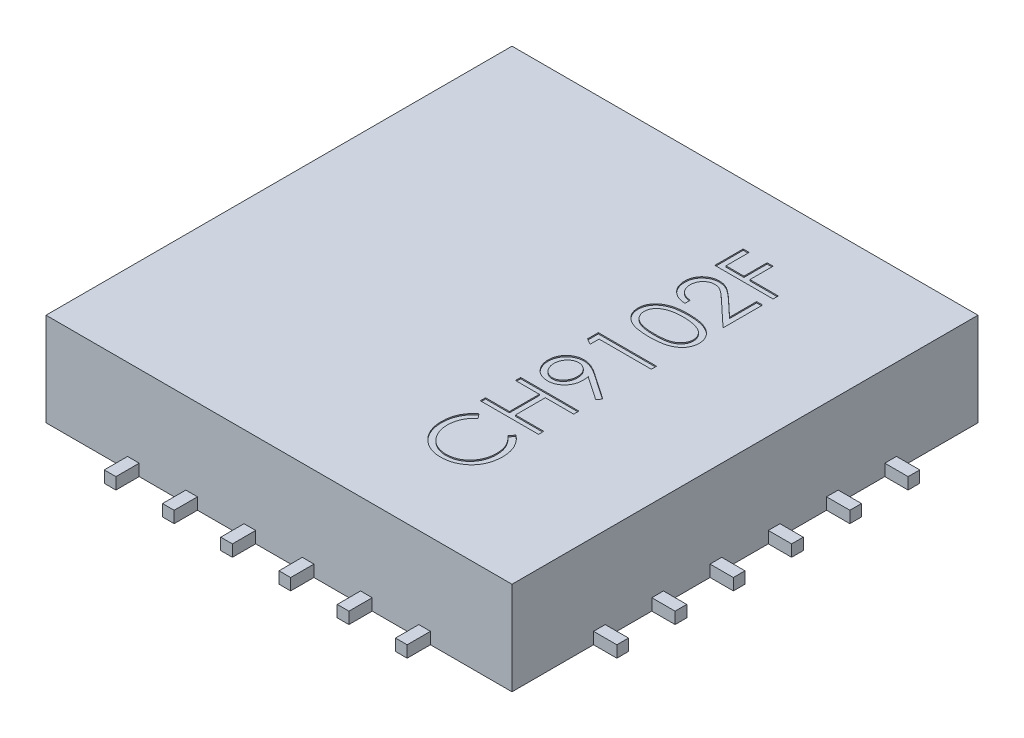
from build123d import *

# Parameters (mm, degrees)
BASES_W                = 4
BASES_H                = 4
BASE_DEPTH             = 0.8
SOLDERCONNECTIONS_W    = 0.2
SOLDERCONNECTIONS_H    = 0.1
SOLDERCONNECTION_DEPTH = 0.1
SC_CP_COUNT            = 4
PARTNO_DEPTH           = 0.01


with BuildPart() as part:
    # BaseS → Base (new body)
    with BuildSketch(Plane(origin=(0, 0, 0), x_dir=(1, 0, 0), z_dir=(0, 1, 0))):
        Rectangle(BASES_W, BASES_H)
    extrude(amount=BASE_DEPTH)

    # SolderConnectionS → SolderConnection (add)
    with BuildSketch(Plane(origin=(0, 0, 0), x_dir=(1, 0, 0), z_dir=(0, 1, 0))):
        with Locations((2.1, -1.25)):
            Rectangle(SOLDERCONNECTIONS_W, SOLDERCONNECTIONS_H)
        with Locations((2.1, -0.75)):
            Rectangle(SOLDERCONNECTIONS_W, SOLDERCONNECTIONS_H)
        with Locations((2.1, -0.25)):
            Rectangle(SOLDERCONNECTIONS_W, SOLDERCONNECTIONS_H)
        with Locations((2.1, 0.25)):
            Rectangle(SOLDERCONNECTIONS_W, SOLDERCONNECTIONS_H)
        with Locations((2.1, 0.75)):
            Rectangle(SOLDERCONNECTIONS_W, SOLDERCONNECTIONS_H)
        with Locations((2.1, 1.25)):
            Rectangle(SOLDERCONNECTIONS_W, SOLDERCONNECTIONS_H)
    solderconnection = extrude(amount=SOLDERCONNECTION_DEPTH)

    # SC CP: SolderConnection ×4 about axis
    sc_cp_axis = Axis((0, 0.84, 0), (0, -1, 0))
    for i in range(1, SC_CP_COUNT):
        add(solderconnection.rotate(sc_cp_axis, i * 360 / SC_CP_COUNT))

    # PartNoS → PartNo (cut)
    # profile 1 of 7: a face of its own
    with BuildSketch(Plane(origin=(0, 0.8, 0), x_dir=(1, 0, 0), z_dir=(0, 1, 0))):
        with BuildLine():
            Line((0.591746795, -0.874358974), (0.621794872, -0.913621795))
            add(Edge.make_bspline(
                [(0.621794872, -0.913621795), (0.61845692, -0.916422665), (0.61182602, -0.921986643), (0.602514008, -0.930937535), (0.593792826, -0.94026792), (0.58560644, -0.949964815), (0.578283878, -0.960252628), (0.571254852, -0.970739365), (0.565100698, -0.981806055), (0.557582628, -0.997031465), (0.54990858, -1.017026558), (0.543308235, -1.042110107), (0.53914621, -1.068330939), (0.538692376, -1.086215626), (0.538461538, -1.0953125)],
                knots=[0, 0, 0, 0, 0.75789156, 1.505565099, 2.245254514, 2.979266606, 3.711207489, 4.440978832, 5.174393176, 5.91211879, 7.394186119, 8.890401545, 10.418332761, 12, 12, 12, 12], degree=3))
            add(Edge.make_bspline(
                [(0.538461538, -1.0953125), (0.538519247, -1.1003244), (0.53863413, -1.110301685), (0.540149719, -1.125108609), (0.542279892, -1.139639045), (0.545440652, -1.15388354), (0.549436741, -1.167823963), (0.5542118, -1.181551449), (0.560119633, -1.194867251), (0.566649391, -1.207955562), (0.574024716, -1.220495481), (0.582069568, -1.232360371), (0.590693407, -1.243507651), (0.599930445, -1.253943597), (0.609732138, -1.263688239), (0.620208298, -1.272618954), (0.631246931, -1.280855063), (0.642857204, -1.288349628), (0.654930986, -1.295096476), (0.667537211, -1.300769527), (0.680460033, -1.305724331), (0.693791068, -1.309706707), (0.70744171, -1.312834341), (0.72146851, -1.314996643), (0.735844874, -1.316494668), (0.745589045, -1.316609023), (0.750500801, -1.316666667)],
                knots=[0, 0, 0, 0, 1.054877232, 2.099964208, 3.13098259, 4.145888998, 5.169474743, 6.183358035, 7.203388855, 8.234598956, 9.261847606, 10.264062591, 11.251197969, 12.227332808, 13.196685059, 14.158975844, 15.123498106, 16.094582253, 17.066912473, 18.032714859, 19.002806091, 19.979168736, 20.95977404, 21.949109834, 22.966205168, 24, 24, 24, 24], degree=3))
            add(Edge.make_bspline(
                [(0.750500801, -1.316666667), (0.757890825, -1.316485984), (0.772400157, -1.316131238), (0.79365544, -1.312987476), (0.814037562, -1.308171849), (0.833408519, -1.3010727), (0.85192979, -1.292144394), (0.869376768, -1.28100433), (0.886005055, -1.268053353), (0.901411924, -1.2531586), (0.915485114, -1.23681448), (0.927878107, -1.219279179), (0.93820879, -1.200595679), (0.946805358, -1.180970454), (0.953413461, -1.160252436), (0.958065479, -1.138478893), (0.961100076, -1.115697179), (0.961390603, -1.100130122), (0.961538462, -1.092207532)],
                knots=[0, 0, 0, 0, 1.029159485, 2.020618137, 2.987588728, 3.942669054, 4.889339625, 5.846988364, 6.821327795, 7.821533711, 8.827683044, 9.822769455, 10.807800696, 11.797391277, 12.803701919, 13.832062008, 14.896664671, 16, 16, 16, 16], degree=3))
            add(Edge.make_bspline(
                [(0.961538462, -1.092207532), (0.961297207, -1.083478576), (0.960822361, -1.066297904), (0.956799611, -1.041102471), (0.950277052, -1.016983076), (0.941148777, -0.993938421), (0.929282307, -0.972033472), (0.914896896, -0.951233949), (0.897855706, -0.931522296), (0.88484383, -0.919669256), (0.878205128, -0.913621795)],
                knots=[0, 0, 0, 0, 1.028121516, 2.023589091, 2.998037872, 3.967518031, 4.937445131, 5.927275754, 6.942489185, 8, 8, 8, 8], degree=3))
            Line((0.878205128, -0.913621795), (0.907952724, -0.874358974))
            add(Edge.make_bspline(
                [(0.907952724, -0.874358974), (0.912029505, -0.877518815), (0.920163539, -0.883823361), (0.931633018, -0.894030006), (0.942411492, -0.904790044), (0.952445132, -0.916131133), (0.961775469, -0.928073262), (0.970407573, -0.940615336), (0.978295631, -0.953746648), (0.9855412, -0.967362898), (0.991920677, -0.981495461), (0.997573827, -0.996019924), (1.00225401, -1.011025341), (1.006212919, -1.0263854), (1.0090358, -1.042238824), (1.011283721, -1.058401329), (1.012617355, -1.075024191), (1.012752186, -1.086228946), (1.012820513, -1.091907051)],
                knots=[0, 0, 0, 0, 0.986911346, 1.969095443, 2.935967484, 3.900112155, 4.865124501, 5.834589912, 6.812044781, 7.795288262, 8.784678562, 9.777857908, 10.776141921, 11.791195789, 12.811324908, 13.855933174, 14.913475973, 16, 16, 16, 16], degree=3))
            add(Edge.make_bspline(
                [(1.012820513, -1.091907051), (1.012783085, -1.097284718), (1.012709077, -1.107918388), (1.011510196, -1.12361821), (1.009874519, -1.138902436), (1.007411643, -1.153727382), (1.004505309, -1.16817395), (1.000609415, -1.182111176), (0.996245249, -1.195676206), (0.991115965, -1.208814541), (0.985327939, -1.221537355), (0.978786288, -1.233803614), (0.971546021, -1.245607676), (0.963766734, -1.257065593), (0.955198548, -1.268008105), (0.945960457, -1.278530037), (0.936083599, -1.288690391), (0.928961477, -1.294976489), (0.925380609, -1.298137019)],
                knots=[0, 0, 0, 0, 1.114604814, 2.203992996, 3.262667896, 4.300477797, 5.318619304, 6.316056647, 7.298880507, 8.271930387, 9.238335007, 10.195173496, 11.151986948, 12.108099108, 13.064862484, 14.031167946, 15.010108607, 16, 16, 16, 16], degree=3))
            add(Edge.make_bspline(
                [(0.925380609, -1.298137019), (0.919160311, -1.303198924), (0.906794811, -1.313261621), (0.886755846, -1.32614158), (0.865852099, -1.337129997), (0.843962492, -1.346113713), (0.821078516, -1.353014256), (0.797236984, -1.357865786), (0.772485557, -1.360996471), (0.755651967, -1.361355808), (0.747095353, -1.361538462)],
                knots=[0, 0, 0, 0, 0.994611881, 1.977215934, 2.950189954, 3.921972279, 4.908960509, 5.911694611, 6.938501887, 8, 8, 8, 8], degree=3))
            add(Edge.make_bspline(
                [(0.747095353, -1.361538462), (0.738101716, -1.361316291), (0.720407299, -1.360879184), (0.694439591, -1.357165499), (0.66956082, -1.351191386), (0.645817428, -1.342706116), (0.62308453, -1.331948208), (0.601535787, -1.318658692), (0.581033387, -1.302991958), (0.561888422, -1.285070877), (0.544382801, -1.2654184), (0.528981914, -1.244372855), (0.516165126, -1.221975434), (0.505451389, -1.198472884), (0.497216466, -1.173689215), (0.491451725, -1.147677305), (0.487863565, -1.120486032), (0.487409964, -1.101934257), (0.487179487, -1.092508013)],
                knots=[0, 0, 0, 0, 1.032925535, 2.032216505, 3.007276963, 3.968222605, 4.92396291, 5.891752235, 6.871517503, 7.883894988, 8.900124299, 9.891468569, 10.874487609, 11.85992873, 12.854644235, 13.869047385, 14.917252991, 16, 16, 16, 16], degree=3))
            add(Edge.make_bspline(
                [(0.487179487, -1.092508013), (0.487248424, -1.086763107), (0.487384877, -1.075391645), (0.488713458, -1.058569564), (0.49093288, -1.042193093), (0.493937831, -1.026245008), (0.49772196, -1.010679203), (0.502438198, -0.995524798), (0.50805321, -0.980818903), (0.514465294, -0.966566295), (0.521675646, -0.952863187), (0.529599217, -0.939718182), (0.538195972, -0.927183685), (0.547553922, -0.915324846), (0.557595444, -0.904127155), (0.568202916, -0.893424504), (0.579648533, -0.883528439), (0.587706659, -0.877421058), (0.591746795, -0.874358974)],
                knots=[0, 0, 0, 0, 1.096622143, 2.170653093, 3.219033441, 4.250379162, 5.267604342, 6.275621678, 7.278284436, 8.271072515, 9.257558938, 10.232633088, 11.19973724, 12.157384997, 13.114417402, 14.069920322, 15.032307892, 16, 16, 16, 16], degree=3))
        make_face()
    # profile 2 of 7: a face of its own
    with BuildSketch(Plane(origin=(0, 0.8, 0), x_dir=(1, 0, 0), z_dir=(0, 1, 0))):
        Polygon((0.5, -0.771794872), (0.5, -0.726923077), (0.705128205, -0.726923077), (0.705128205, -0.470512821), (0.5, -0.470512821), (0.5, -0.425641026), (1, -0.425641026), (1, -0.470512821), (0.756410256, -0.470512821), (0.756410256, -0.726923077), (1, -0.726923077), (1, -0.771794872), align=None)
    # profile 3 of 7: a face of its own
    with BuildSketch(Plane(origin=(0, 0.8, 0), x_dir=(1, 0, 0), z_dir=(0, 1, 0))):
        with BuildLine():
            Line((1.012820513, -0.233333333), (0.987880609, -0.269190705))
            Line((0.987880609, -0.269190705), (0.784655449, -0.130168269))
            add(Edge.make_bspline(
                [(0.784655449, -0.130168269), (0.785790787, -0.139037148), (0.788025738, -0.156495828), (0.788317828, -0.174093981), (0.788461538, -0.182752404)],
                knots=[0, 0, 0, 0, 1.015985029, 2, 2, 2, 2], degree=3))
            add(Edge.make_bspline(
                [(0.788461538, -0.182752404), (0.788327099, -0.188001268), (0.788063206, -0.198304329), (0.785971519, -0.213451708), (0.782750072, -0.228006787), (0.777943108, -0.241930983), (0.771969074, -0.255276619), (0.764560944, -0.268014608), (0.755845706, -0.28012762), (0.745869767, -0.291486259), (0.734915007, -0.301814888), (0.723324059, -0.311024054), (0.7109718, -0.318635903), (0.698118741, -0.325071955), (0.684490548, -0.329816081), (0.670318466, -0.333354258), (0.655514522, -0.335508706), (0.645439817, -0.33576653), (0.640324519, -0.335897436)],
                knots=[0, 0, 0, 0, 1.060698949, 2.082059282, 3.085738422, 4.069684654, 5.054463875, 6.037298355, 7.043153692, 8.066652628, 9.088369706, 10.083456696, 11.053578809, 12.016466116, 12.983507685, 13.964045196, 14.966270913, 16, 16, 16, 16], degree=3))
            add(Edge.make_bspline(
                [(0.640324519, -0.335897436), (0.633329267, -0.335649162), (0.619599006, -0.335161849), (0.599533201, -0.331254862), (0.580549623, -0.324781706), (0.5626695, -0.315897636), (0.546303538, -0.30449332), (0.531507187, -0.29094985), (0.518544391, -0.275157764), (0.507414305, -0.257529366), (0.498401842, -0.238504098), (0.49199887, -0.218496083), (0.487908503, -0.197842369), (0.48742354, -0.183806313), (0.487179487, -0.176742788)],
                knots=[0, 0, 0, 0, 1.023011052, 2.007963168, 2.978169221, 3.950402619, 4.919353283, 5.887490769, 6.876420893, 7.899700203, 8.931203047, 9.947778163, 10.96723692, 12, 12, 12, 12], degree=3))
            add(Edge.make_bspline(
                [(0.487179487, -0.176742788), (0.48744094, -0.169815874), (0.487957548, -0.156128943), (0.491740951, -0.136001909), (0.498117696, -0.116724746), (0.506929484, -0.098403563), (0.517976414, -0.081442535), (0.531134515, -0.06618246), (0.546414776, -0.053028286), (0.563397451, -0.041813326), (0.581756797, -0.032978529), (0.600884185, -0.026504866), (0.620664562, -0.022547747), (0.634063312, -0.02204739), (0.640825321, -0.021794872)],
                knots=[0, 0, 0, 0, 1.026358223, 2.027987109, 3.023239252, 4.028077889, 5.032770297, 6.015020143, 7.004250571, 8.011656937, 9.02310243, 10.015224881, 10.998334443, 12, 12, 12, 12], degree=3))
            add(Edge.make_bspline(
                [(0.640825321, -0.021794872), (0.646074237, -0.021963966), (0.656720351, -0.02230693), (0.672866992, -0.02468125), (0.689317131, -0.028776795), (0.703254148, -0.033352999), (0.714800217, -0.03783845), (0.723947545, -0.041938814), (0.733508622, -0.046701952), (0.743522598, -0.052021508), (0.754002539, -0.057887402), (0.764875759, -0.064459097), (0.776158111, -0.071647954), (0.783765009, -0.076766154), (0.787660256, -0.079387019)],
                knots=[0, 0, 0, 0, 1.179894106, 2.393120058, 3.660107319, 4.986885617, 5.687958251, 6.443931318, 7.239444731, 8.088894906, 8.992865148, 9.938946712, 10.944601238, 12, 12, 12, 12], degree=3))
            Line((0.787660256, -0.079387019), (1.012820513, -0.233333333))
        make_face()
        with BuildLine():
            add(Edge.make_bspline(
                [(0.737179487, -0.174439103), (0.737070636, -0.17046291), (0.736858739, -0.162722616), (0.735574826, -0.151381677), (0.73328159, -0.140682988), (0.730043221, -0.130557689), (0.725940854, -0.121018039), (0.720941448, -0.112061033), (0.714935477, -0.103778163), (0.708184646, -0.09613994), (0.700786003, -0.08920802), (0.692859043, -0.083231108), (0.684650031, -0.078056184), (0.675990916, -0.073927751), (0.667023352, -0.070600657), (0.657617648, -0.068279127), (0.647838748, -0.066996914), (0.641196159, -0.066777944), (0.637820513, -0.066666667)],
                knots=[0, 0, 0, 0, 1.163726718, 2.265380301, 3.334713825, 4.36057981, 5.371541381, 6.368955992, 7.355979581, 8.359691305, 9.348261197, 10.317521986, 11.261029684, 12.183096459, 13.119698615, 14.055740009, 15.011961376, 16, 16, 16, 16], degree=3))
            add(Edge.make_bspline(
                [(0.637820513, -0.066666667), (0.634443372, -0.066762241), (0.6277883, -0.066950582), (0.617996145, -0.068464386), (0.608608921, -0.071120172), (0.599562722, -0.074719659), (0.590907002, -0.07937145), (0.58261448, -0.085007734), (0.574810677, -0.091813667), (0.567366978, -0.099418993), (0.560614284, -0.107783942), (0.554648109, -0.116646658), (0.549612984, -0.125959794), (0.545636956, -0.135764897), (0.542379653, -0.145928815), (0.54007378, -0.15655677), (0.538789129, -0.167663449), (0.538572126, -0.175203804), (0.538461538, -0.179046474)],
                knots=[0, 0, 0, 0, 0.971910406, 1.91526867, 2.84337505, 3.775008003, 4.712374136, 5.666733183, 6.654995996, 7.688089235, 8.726800303, 9.745078658, 10.75990398, 11.768337501, 12.786615857, 13.829099629, 14.893678693, 16, 16, 16, 16], degree=3))
            add(Edge.make_bspline(
                [(0.538461538, -0.179046474), (0.538572308, -0.182855725), (0.538789636, -0.190329443), (0.540071312, -0.20133739), (0.542395318, -0.211893466), (0.54563548, -0.222027881), (0.549613288, -0.231832699), (0.554648375, -0.241145396), (0.5606129, -0.250010176), (0.567372355, -0.258367168), (0.574775966, -0.265986202), (0.582649351, -0.272676968), (0.590902612, -0.278325999), (0.599563881, -0.282971291), (0.608608612, -0.286572497), (0.617996228, -0.289227824), (0.627788279, -0.290741751), (0.634443364, -0.290930075), (0.637820513, -0.291025641)],
                knots=[0, 0, 0, 0, 1.099107991, 2.156440826, 3.191784126, 4.212280276, 5.222910149, 6.239945746, 7.260441896, 8.30141526, 9.33675856, 10.320924759, 11.277362386, 12.216770088, 13.150432123, 14.080559904, 15.025972789, 16, 16, 16, 16], degree=3))
            add(Edge.make_bspline(
                [(0.637820513, -0.291025641), (0.641198778, -0.290938986), (0.647861335, -0.290768087), (0.657651527, -0.289122614), (0.667032917, -0.286363524), (0.676085589, -0.282704955), (0.684692425, -0.277795051), (0.692898054, -0.271828098), (0.700870231, -0.264943252), (0.708161512, -0.256914882), (0.714967788, -0.248293802), (0.720903685, -0.239033843), (0.725881118, -0.229321089), (0.730055314, -0.219217904), (0.733248924, -0.208648688), (0.735570566, -0.197628159), (0.73684643, -0.186154331), (0.737067403, -0.178381644), (0.737179487, -0.174439103)],
                knots=[0, 0, 0, 0, 0.952872936, 1.879239831, 2.791748947, 3.708674669, 4.628500839, 5.580394867, 6.568761142, 7.595635223, 8.636123962, 9.665976811, 10.694276597, 11.712685318, 12.747011694, 13.805940053, 14.887106426, 16, 16, 16, 16], degree=3))
        make_face(mode=Mode.SUBTRACT)
    # profile 4 of 7: a face of its own
    with BuildSketch(Plane(origin=(0, 0.8, 0), x_dir=(1, 0, 0), z_dir=(0, 1, 0))):
        Polygon((0.5, 0.148577724), (0.5, 0.241025641), (1, 0.241025641), (1, 0.196153846), (0.551282051, 0.196153846), (0.551282051, 0.119230769), align=None)
    # profile 5 of 7: a face of its own
    with BuildSketch(Plane(origin=(0, 0.8, 0), x_dir=(1, 0, 0), z_dir=(0, 1, 0))):
        with BuildLine():
            add(Edge.make_bspline(
                [(0.750200321, 0.426923077), (0.742186408, 0.426969937), (0.726619267, 0.427060962), (0.703935747, 0.428073594), (0.682655706, 0.429755786), (0.662778125, 0.432061125), (0.644297873, 0.43486655), (0.627264337, 0.438611621), (0.611598675, 0.442870589), (0.597249824, 0.447806665), (0.584024393, 0.453376307), (0.571678095, 0.459438492), (0.560228683, 0.466232937), (0.549496731, 0.473374376), (0.539646148, 0.481140825), (0.530563435, 0.489365757), (0.52232519, 0.49821367), (0.514925769, 0.507598749), (0.508437557, 0.517457386), (0.502687322, 0.527520182), (0.497950884, 0.537966937), (0.494076347, 0.548660125), (0.490913473, 0.559622282), (0.488740903, 0.570850611), (0.487376356, 0.58237114), (0.487245733, 0.590147014), (0.487179487, 0.594090545)],
                knots=[0, 0, 0, 0, 1.646148282, 3.197666765, 4.66315463, 6.030252048, 7.307778049, 8.501004361, 9.610818041, 10.641065266, 11.615491391, 12.557119604, 13.464013759, 14.348536654, 15.203310953, 16.038349431, 16.863300206, 17.683791446, 18.490318933, 19.285717724, 20.06220424, 20.843281102, 21.620494212, 22.403315558, 23.190242141, 24, 24, 24, 24], degree=3))
            add(Edge.make_bspline(
                [(0.487179487, 0.594090545), (0.487234666, 0.59806897), (0.487344452, 0.605984637), (0.488889754, 0.617645372), (0.490884321, 0.629102997), (0.494083278, 0.640183678), (0.497911245, 0.651096928), (0.502962186, 0.661571356), (0.508455477, 0.671976767), (0.51515683, 0.681840454), (0.522562927, 0.691457129), (0.530970742, 0.700471757), (0.540147585, 0.709114777), (0.550298129, 0.717059746), (0.561266734, 0.724647173), (0.57314535, 0.731589032), (0.585907651, 0.738029701), (0.599494474, 0.744090249), (0.614268744, 0.749390037), (0.630138309, 0.754101973), (0.647246877, 0.757964201), (0.665499142, 0.761158196), (0.684985524, 0.763637344), (0.705666543, 0.765441626), (0.727555137, 0.766395033), (0.742520549, 0.766574546), (0.750200321, 0.766666667)],
                knots=[0, 0, 0, 0, 0.810910589, 1.61342667, 2.396193133, 3.181089899, 3.963115317, 4.752255436, 5.550715454, 6.36105385, 7.181178335, 8.024612154, 8.872680183, 9.750181803, 10.651284446, 11.591556747, 12.554036451, 13.566402641, 14.62422919, 15.753422176, 16.94128843, 18.199818041, 19.531985927, 20.947085226, 22.433341622, 24, 24, 24, 24], degree=3))
            add(Edge.make_bspline(
                [(0.750200321, 0.766666667), (0.757846526, 0.766572519), (0.772778195, 0.766388667), (0.794569328, 0.765462074), (0.815138872, 0.763593274), (0.834508757, 0.761289742), (0.852687965, 0.758060048), (0.86966465, 0.754168534), (0.885498916, 0.749734732), (0.900077314, 0.744353607), (0.913640559, 0.738434124), (0.926309021, 0.732000365), (0.938184499, 0.72509768), (0.949182036, 0.717624047), (0.959291837, 0.709548392), (0.968500155, 0.70091143), (0.976961447, 0.691818093), (0.984449138, 0.682145355), (0.991201511, 0.672189793), (0.99689415, 0.661783326), (1.001826488, 0.651192283), (1.00585913, 0.640310922), (1.00898649, 0.629156045), (1.01113638, 0.617690567), (1.012647587, 0.605982991), (1.012762671, 0.59806842), (1.012820513, 0.594090545)],
                knots=[0, 0, 0, 0, 1.561645053, 3.049612875, 4.452756685, 5.778837748, 7.032101753, 8.221335837, 9.334924186, 10.387562255, 11.392109817, 12.355697819, 13.287721948, 14.19548756, 15.068665045, 15.927346723, 16.771751757, 17.602390507, 18.423119567, 19.225778204, 20.022010933, 20.807278863, 21.593079439, 22.384715467, 23.188155646, 24, 24, 24, 24], degree=3))
            add(Edge.make_bspline(
                [(1.012820513, 0.594090545), (1.012753891, 0.5901471), (1.012622525, 0.582371396), (1.01126342, 0.570849621), (1.009078348, 0.559666415), (1.006018834, 0.548766593), (1.002273856, 0.538094235), (0.997394763, 0.527794759), (0.991775593, 0.517753686), (0.98537631, 0.507997657), (0.978044402, 0.498710559), (0.969936129, 0.489837981), (0.960843568, 0.481611021), (0.950909871, 0.473911914), (0.940161952, 0.466694977), (0.928592599, 0.459959246), (0.916182057, 0.453769931), (0.902852104, 0.448105133), (0.888401411, 0.443082657), (0.872695816, 0.438663369), (0.855575796, 0.435133819), (0.837128273, 0.43214198), (0.817315764, 0.42974458), (0.796131099, 0.428074292), (0.773614508, 0.427061731), (0.758147473, 0.426970138), (0.750200321, 0.426923077)],
                knots=[0, 0, 0, 0, 0.810927267, 1.598990287, 2.382942141, 3.152806972, 3.926217614, 4.706701772, 5.493896336, 6.292070767, 7.104102563, 7.925577746, 8.761822141, 9.623241997, 10.509042271, 11.423174113, 12.375371989, 13.360203808, 14.400680605, 15.520553799, 16.714061498, 17.994519714, 19.364400916, 20.818312473, 22.365209998, 24, 24, 24, 24], degree=3))
        make_face()
        with BuildLine():
            add(Edge.make_bspline(
                [(0.75, 0.471794872), (0.756678359, 0.47181231), (0.769639742, 0.471846154), (0.788441574, 0.472704712), (0.806007507, 0.473899737), (0.822330686, 0.475403148), (0.837354061, 0.47765472), (0.851140091, 0.480209265), (0.863663256, 0.483273287), (0.875032996, 0.48691645), (0.88541031, 0.491066367), (0.89507179, 0.495589393), (0.904131943, 0.500491465), (0.912568787, 0.505873065), (0.920279192, 0.511840592), (0.927458599, 0.518117391), (0.933857314, 0.524986226), (0.941532851, 0.534486339), (0.949464027, 0.547028892), (0.95637065, 0.562831754), (0.960710992, 0.579070119), (0.961262958, 0.590091724), (0.961538462, 0.595592949)],
                knots=[0, 0, 0, 0, 1.459098681, 2.831824031, 4.11146945, 5.306290378, 6.412266529, 7.42953815, 8.369053297, 9.227277979, 10.03601793, 10.809473603, 11.557037441, 12.285528272, 12.993193355, 13.685654407, 14.36688038, 15.041354379, 16.352855396, 17.594313975, 18.799247529, 20, 20, 20, 20], degree=3))
            add(Edge.make_bspline(
                [(0.961538462, 0.595592949), (0.961297225, 0.601126018), (0.960815608, 0.61217253), (0.956612246, 0.628395978), (0.949778915, 0.644015476), (0.941971995, 0.656342219), (0.934489611, 0.665694161), (0.928117514, 0.672397146), (0.920980565, 0.678548712), (0.913280776, 0.684383338), (0.90487039, 0.689734622), (0.895790031, 0.694600788), (0.886014432, 0.699041265), (0.879190184, 0.701571129), (0.875701122, 0.702864583)],
                knots=[0, 0, 0, 0, 1.353621445, 2.702441307, 4.075953605, 5.516772412, 6.261413105, 7.007624062, 7.778524365, 8.566925914, 9.372323995, 10.217594641, 11.088702136, 12, 12, 12, 12], degree=3))
            add(Edge.make_bspline(
                [(0.875701122, 0.702864583), (0.87123973, 0.704371979), (0.862181193, 0.707432638), (0.848129242, 0.711377177), (0.83338599, 0.714483663), (0.818039545, 0.717278429), (0.801976731, 0.719186009), (0.785247247, 0.72072141), (0.767838481, 0.721625794), (0.756010625, 0.721737902), (0.75, 0.721794872)],
                knots=[0, 0, 0, 0, 0.884706709, 1.796334032, 2.740027952, 3.714592787, 4.726048262, 5.777819803, 6.87074269, 8, 8, 8, 8], degree=3))
            add(Edge.make_bspline(
                [(0.75, 0.721794872), (0.743990347, 0.721716273), (0.73223418, 0.721562518), (0.715017297, 0.720974805), (0.69866476, 0.719457152), (0.683106121, 0.717771563), (0.668427506, 0.715286246), (0.654506035, 0.712606559), (0.641514171, 0.709006389), (0.62924853, 0.705160694), (0.617848388, 0.700759256), (0.607260872, 0.695913987), (0.597433895, 0.690740022), (0.588397817, 0.685117703), (0.580100227, 0.679125343), (0.57273205, 0.67254809), (0.565934867, 0.665803648), (0.558314722, 0.65621163), (0.550483765, 0.643756103), (0.543473281, 0.628150309), (0.539324288, 0.611998985), (0.538748914, 0.601057684), (0.538461538, 0.595592949)],
                knots=[0, 0, 0, 0, 1.313483664, 2.569454835, 3.763100662, 4.901599063, 5.988328865, 7.015709358, 7.99797933, 8.932480776, 9.824041341, 10.666387587, 11.475829342, 12.24921787, 12.990555181, 13.709176526, 14.405678811, 15.080244297, 16.38186033, 17.610124501, 18.806354173, 20, 20, 20, 20], degree=3))
            add(Edge.make_bspline(
                [(0.538461538, 0.595592949), (0.538749629, 0.590062024), (0.539326335, 0.578990099), (0.543454094, 0.562666294), (0.550463254, 0.546955073), (0.558299635, 0.534458472), (0.56590565, 0.524982981), (0.572379245, 0.51825895), (0.579387175, 0.511895101), (0.58716598, 0.506082103), (0.595573097, 0.500732413), (0.604516086, 0.495640894), (0.614195619, 0.491178353), (0.624564796, 0.487015113), (0.635935161, 0.483365873), (0.648503639, 0.480336861), (0.662322591, 0.477579304), (0.677455735, 0.475593414), (0.693782398, 0.473844705), (0.711393253, 0.472717831), (0.730259649, 0.471842221), (0.743288092, 0.471810971), (0.75, 0.471794872)],
                knots=[0, 0, 0, 0, 1.207546505, 2.417292871, 3.651582144, 4.952510111, 5.626719005, 6.30238548, 6.989136872, 7.692112372, 8.420316868, 9.164734959, 9.937886623, 10.746308695, 11.604196049, 12.543341915, 13.568754172, 14.680483261, 15.875568977, 17.154711427, 18.534182925, 20, 20, 20, 20], degree=3))
        make_face(mode=Mode.SUBTRACT)
    # profile 6 of 7: a face of its own
    with BuildSketch(Plane(origin=(0, 0.8, 0), x_dir=(1, 0, 0), z_dir=(0, 1, 0))):
        with BuildLine():
            Line((0.653846154, 0.875641026), (0.653846154, 0.830769231))
            add(Edge.make_bspline(
                [(0.653846154, 0.830769231), (0.64789317, 0.831061681), (0.636201668, 0.831636046), (0.619155395, 0.834325802), (0.602861853, 0.838174498), (0.587451865, 0.843616135), (0.572789178, 0.850374174), (0.558932033, 0.858478464), (0.545933292, 0.868077586), (0.533913457, 0.878964262), (0.522886661, 0.890788353), (0.513364484, 0.903546344), (0.505319102, 0.916952777), (0.498593211, 0.930966977), (0.493544661, 0.945747057), (0.489798713, 0.961158894), (0.487544949, 0.977270199), (0.487302694, 0.988247345), (0.487179487, 0.993830128)],
                knots=[0, 0, 0, 0, 1.10065271, 2.161652631, 3.183658789, 4.190468796, 5.17591951, 6.163126047, 7.15150782, 8.156236427, 9.156009102, 10.134482811, 11.092018607, 12.041330605, 13.001268258, 13.972401359, 14.968799086, 16, 16, 16, 16], degree=3))
            add(Edge.make_bspline(
                [(0.487179487, 0.993830128), (0.487306797, 0.999313096), (0.487556955, 1.010086932), (0.489737551, 1.025804619), (0.49307912, 1.040803061), (0.498030799, 1.054912283), (0.504244073, 1.068277084), (0.511971093, 1.080731985), (0.520846243, 1.092578159), (0.531314917, 1.103234217), (0.54248502, 1.113023091), (0.554414595, 1.12146051), (0.566750143, 1.12872688), (0.579588022, 1.134674178), (0.59297004, 1.139182494), (0.606767897, 1.142522724), (0.62114083, 1.14443218), (0.630870618, 1.144723623), (0.635817308, 1.144871795)],
                knots=[0, 0, 0, 0, 1.111674182, 2.184400057, 3.212814286, 4.223731311, 5.211378316, 6.196328225, 7.191884489, 8.207283132, 9.220262353, 10.201199469, 11.166417575, 12.120932471, 13.06540007, 14.026332106, 14.996573967, 16, 16, 16, 16], degree=3))
            add(Edge.make_bspline(
                [(0.635817308, 1.144871795), (0.642781281, 1.144629896), (0.65658702, 1.144150344), (0.676874901, 1.140048346), (0.696530937, 1.13364149), (0.712351091, 1.125928265), (0.725097526, 1.118144957), (0.735597492, 1.111138082), (0.746900158, 1.102888726), (0.759051271, 1.093467369), (0.771891701, 1.08271176), (0.785683429, 1.07090133), (0.800171435, 1.057731069), (0.810073385, 1.04849555), (0.815204327, 1.043709936)],
                knots=[0, 0, 0, 0, 1.184416499, 2.348048165, 3.509039915, 4.696071444, 5.333504901, 6.05069495, 6.844171097, 7.714965912, 8.667477798, 9.695072654, 10.805644396, 12, 12, 12, 12], degree=3))
            Line((0.815204327, 1.043709936), (0.948717949, 0.918609776))
            Line((0.948717949, 0.918609776), (0.948717949, 1.151282051))
            Line((0.948717949, 1.151282051), (1, 1.151282051))
            Line((1, 1.151282051), (1, 0.811538462))
            Line((1, 0.811538462), (0.79306891, 1.005448718))
            add(Edge.make_bspline(
                [(0.79306891, 1.005448718), (0.788140581, 1.010169845), (0.778674268, 1.019238163), (0.764853846, 1.032064245), (0.752032483, 1.043584101), (0.740234404, 1.0538723), (0.729287037, 1.062705658), (0.719544937, 1.070544548), (0.710580015, 1.076825347), (0.700188499, 1.083641832), (0.687501025, 1.090243829), (0.671996212, 1.095917023), (0.656035176, 1.099376287), (0.645249171, 1.099791263), (0.639823718, 1.1)],
                knots=[0, 0, 0, 0, 1.329631726, 2.553950428, 3.673215718, 4.687767853, 5.603093632, 6.413772471, 7.123043292, 7.734684054, 8.834405432, 9.900288307, 10.943827018, 12, 12, 12, 12], degree=3))
            add(Edge.make_bspline(
                [(0.639823718, 1.1), (0.63641209, 1.09990918), (0.629688425, 1.09973019), (0.61983046, 1.098150519), (0.610321201, 1.095763304), (0.601131398, 1.092342553), (0.592353448, 1.087827304), (0.583976665, 1.082331107), (0.575878241, 1.07598967), (0.568284913, 1.068653774), (0.561330455, 1.060594985), (0.555169871, 1.052081521), (0.550021427, 1.043074363), (0.545800927, 1.033611489), (0.542490158, 1.023719279), (0.540196076, 1.013378601), (0.538755721, 1.002618027), (0.538560839, 0.995270385), (0.538461538, 0.991526442)],
                knots=[0, 0, 0, 0, 0.991446411, 1.95395049, 2.89581595, 3.838931463, 4.798493298, 5.75982156, 6.748411868, 7.785213223, 8.824556874, 9.840280684, 10.836137867, 11.835679398, 12.848801643, 13.863922112, 14.911575587, 16, 16, 16, 16], degree=3))
            add(Edge.make_bspline(
                [(0.538461538, 0.991526442), (0.538559655, 0.987615342), (0.538752341, 0.979934587), (0.540211836, 0.968681474), (0.542424431, 0.957872368), (0.545938515, 0.947668551), (0.55009058, 0.937849065), (0.555365331, 0.928623542), (0.561494709, 0.919838808), (0.568601973, 0.911639356), (0.576587498, 0.904150647), (0.585388097, 0.897478316), (0.594940414, 0.891686733), (0.605205244, 0.886626573), (0.616284786, 0.882519094), (0.628137194, 0.879379937), (0.640711711, 0.87689614), (0.64939529, 0.876066346), (0.653846154, 0.875641026)],
                knots=[0, 0, 0, 0, 1.030878251, 2.024474673, 2.987898669, 3.934362936, 4.864849709, 5.795128259, 6.730474222, 7.685293701, 8.650606017, 9.611896181, 10.591709709, 11.591680886, 12.625074257, 13.701333388, 14.821793024, 16, 16, 16, 16], degree=3))
        make_face()
    # profile 7 of 7: a face of its own
    with BuildSketch(Plane(origin=(0, 0.8, 0), x_dir=(1, 0, 0), z_dir=(0, 1, 0))):
        Polygon((0.5, 1.241025641), (0.5, 1.484615385), (0.551282051, 1.484615385), (0.551282051, 1.285897436), (0.705128205, 1.285897436), (0.705128205, 1.484615385), (0.756410256, 1.484615385), (0.756410256, 1.285897436), (1, 1.285897436), (1, 1.241025641), align=None)
    extrude(amount=-PARTNO_DEPTH, mode=Mode.SUBTRACT)


solid = part.part
